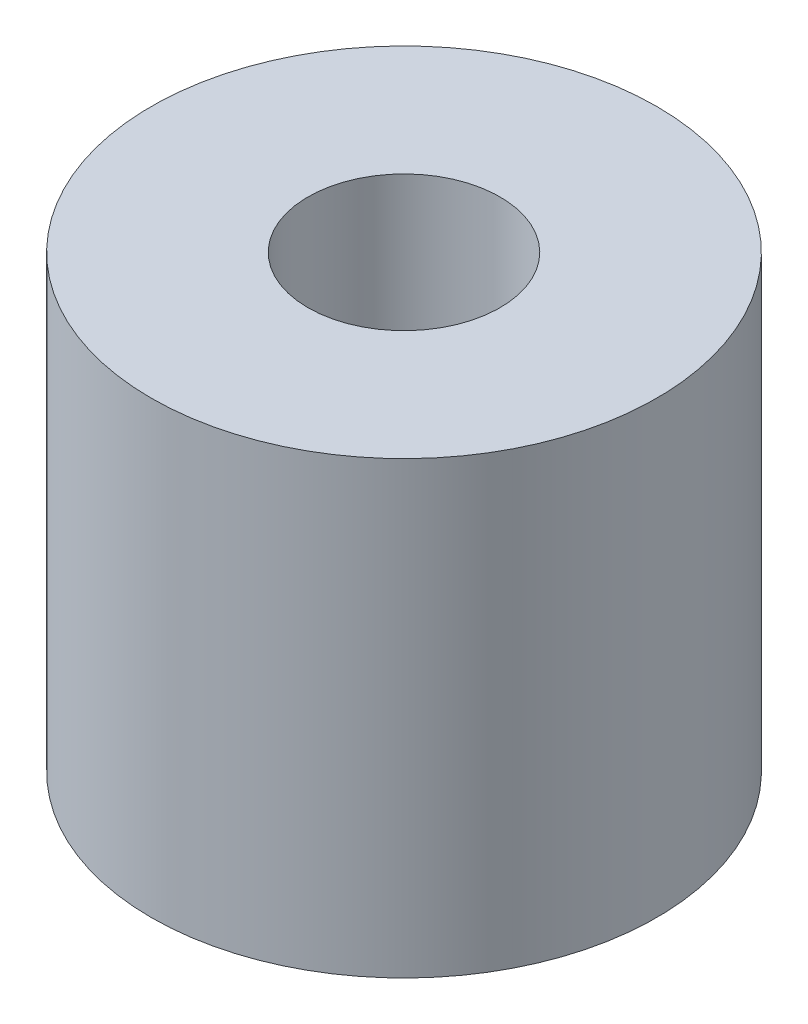
from build123d import *

# Parameters (mm, degrees)
SKETCH1_R           = 12.7
SKETCH1_R_2         = 4.826
BOSS_EXTRUDE1_DEPTH = 22.606


with BuildPart() as part:
    # Sketch1 → Boss-Extrude1 (new body)
    with BuildSketch(Plane(origin=(0, 0, 0), x_dir=(1, 0, 0), z_dir=(0, 1, 0))):
        Circle(SKETCH1_R)
        Circle(SKETCH1_R_2, mode=Mode.SUBTRACT)
    extrude(amount=BOSS_EXTRUDE1_DEPTH)


solid = part.part
